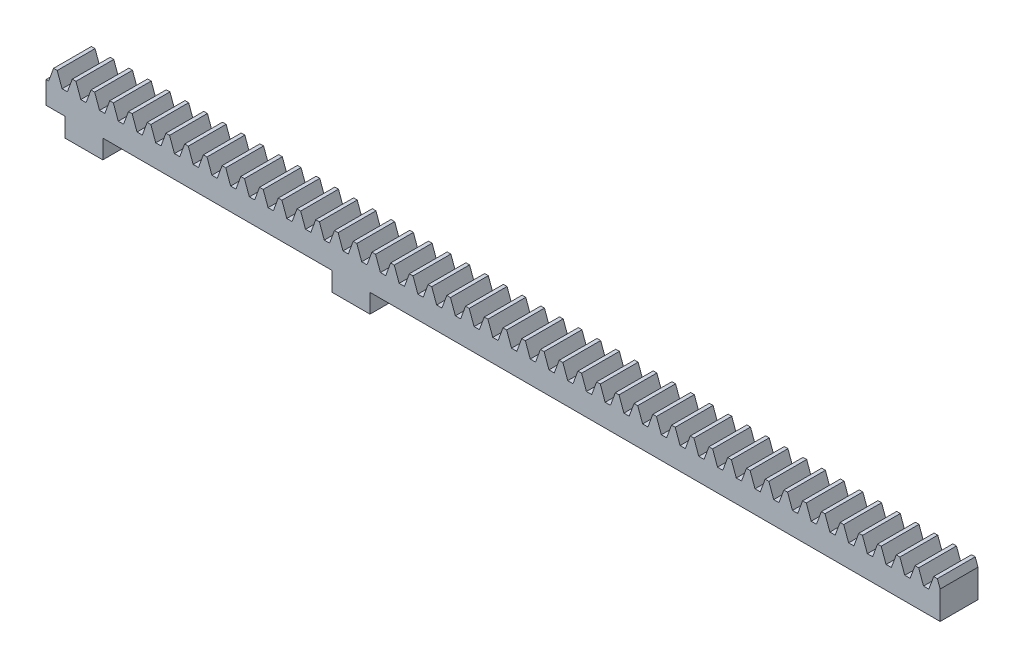
from build123d import *

# Parameters (mm, degrees)
BLANKSKE_W                = 150
BLANKSKE_H                = 6
BLANK_DEPTH               = 6.35
TOOTHCUTSIM_DEPTH         = 151.254192953
TEETHCUTS_COUNT           = 49
TEETHCUTS_PITCH           = 3.14159265
SKETCH1_W                 = 6.35
SKETCH1_H                 = 6.35
ELASTICPEGS_EXTRUDE_DEPTH = 3.175


with BuildPart() as part:
    # BlankSke → Blank (new body)
    with BuildSketch(Plane.XY):
        with Locations((75, 3)):
            Rectangle(BLANKSKE_W, BLANKSKE_H)
    extrude(amount=-BLANK_DEPTH)

    # TooCutSkeSim → ToothCutSim (cut, through all)
    with BuildSketch(Plane.XY):
        Polygon((0.44443537, 3.75), (-0.44443537, 3.75), (-1.272613241, 6.0254), (1.272613241, 6.0254), align=None)
    toothcutsim = extrude(amount=-TOOTHCUTSIM_DEPTH, mode=Mode.SUBTRACT)

    # TeethCuts: ToothCutSim ×49
    with Locations(*[(i * TEETHCUTS_PITCH, 0, 0) for i in range(1, TEETHCUTS_COUNT)]):
        add(toothcutsim, mode=Mode.SUBTRACT)

    # Sketch1 → ElasticPegs_Extrude (add)
    with BuildSketch(Plane.XZ):
        with Locations((51.17500001, -3.175)):
            Rectangle(SKETCH1_W, SKETCH1_H)
        with Locations((6.35, -3.175)):
            Rectangle(SKETCH1_W, SKETCH1_H)
    extrude(amount=ELASTICPEGS_EXTRUDE_DEPTH)


solid = part.part
